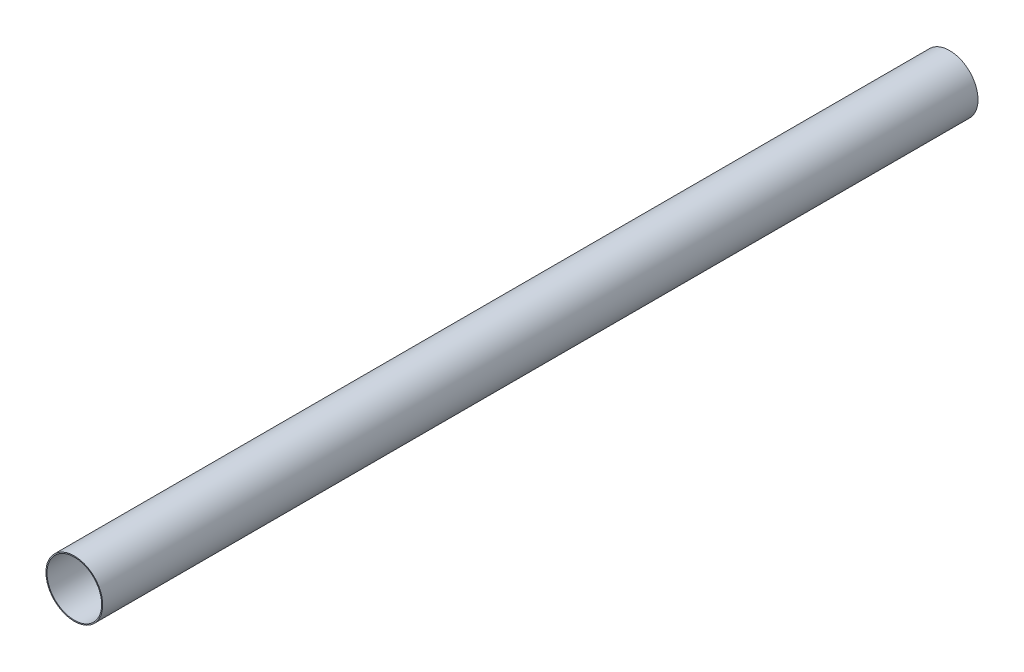
from build123d import *

# Parameters (mm, degrees)
PIPESKETCH_R    = 177.8
PIPESKETCH_R_2  = 171.45
EXTRUSION_DEPTH = 5486.4


with BuildPart() as part:
    # PipeSketch → Extrusion (new body)
    with BuildSketch(Plane.XY):
        Circle(PIPESKETCH_R)
        Circle(PIPESKETCH_R_2, mode=Mode.SUBTRACT)
    extrude(amount=EXTRUSION_DEPTH)


solid = part.part
